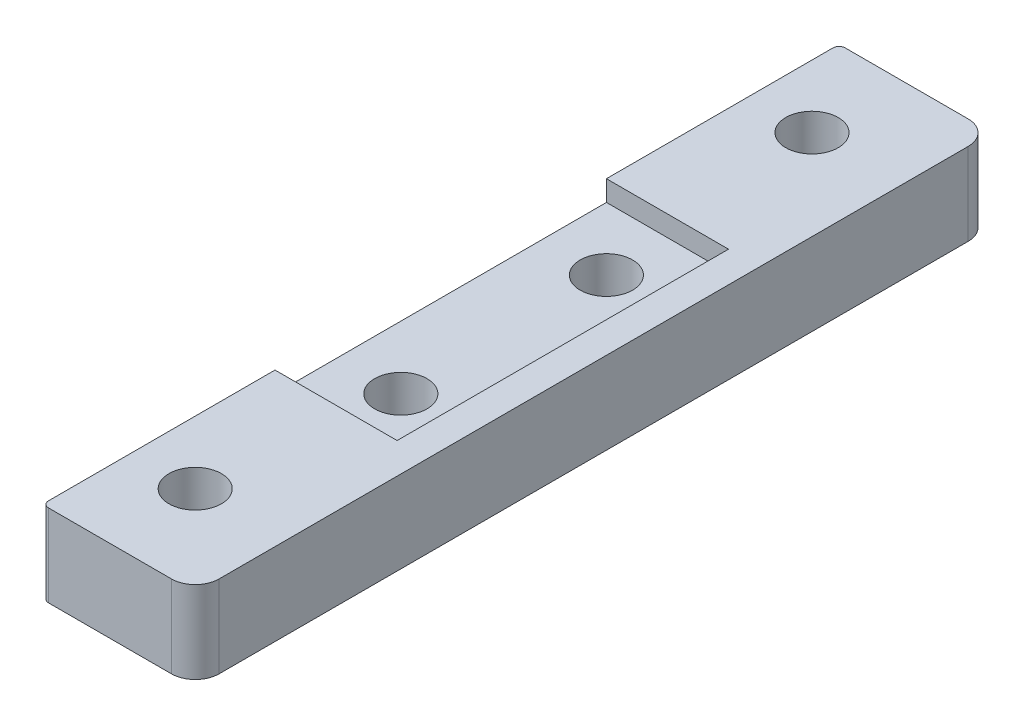
from build123d import *

# Parameters (mm, degrees)
SKETCH1_R           = 2.55
BOSS_EXTRUDE1_DEPTH = 8
SKETCH2_W           = 11.877
SKETCH2_H           = 32.24
CUT_EXTRUDE1_DEPTH  = 2


with BuildPart() as part:
    # Sketch1 → Boss-Extrude1 (new body)
    with BuildSketch(Plane(origin=(0, 0, 0), x_dir=(1, 0, 0), z_dir=(0, 1, 0))):
        with BuildLine():
            Line((-5.97725, 0), (5.97725, 0))
            ThreePointArc((5.97725, 0), (7.615969965, 0.678780035), (8.29475, 2.3175))
            Line((8.29475, 2.3175), (8.29475, 75.1875))
            ThreePointArc((8.29475, 75.1875), (7.615969965, 76.826219965), (5.97725, 77.505))
            Line((5.97725, 77.505), (-5.97725, 77.505))
            ThreePointArc((-5.97725, 77.505), (-6.405049603, 77.327799603), (-6.58225, 76.9))
            Line((-6.58225, 76.9), (-6.58225, 0.605))
            ThreePointArc((-6.58225, 0.605), (-6.405049603, 0.177200397), (-5.97725, 0))
        make_face()
        with Locations((-0.46525, 68.7525)):
            Circle(SKETCH1_R, mode=Mode.SUBTRACT)
        with Locations((-0.46525, 48.7525)):
            Circle(SKETCH1_R, mode=Mode.SUBTRACT)
        with Locations((-0.46525, 8.7525)):
            Circle(SKETCH1_R, mode=Mode.SUBTRACT)
        with Locations((-0.46525, 28.7525)):
            Circle(SKETCH1_R, mode=Mode.SUBTRACT)
    extrude(amount=BOSS_EXTRUDE1_DEPTH)

    # Sketch2 → Cut-Extrude1 (cut)
    with BuildSketch(Plane(origin=(0, 8, 0), x_dir=(1, 0, 0), z_dir=(0, 1, 0))):
        with Locations((-0.64375, 38.7525)):
            Rectangle(SKETCH2_W, SKETCH2_H)
    extrude(amount=-CUT_EXTRUDE1_DEPTH, mode=Mode.SUBTRACT)


solid = part.part
